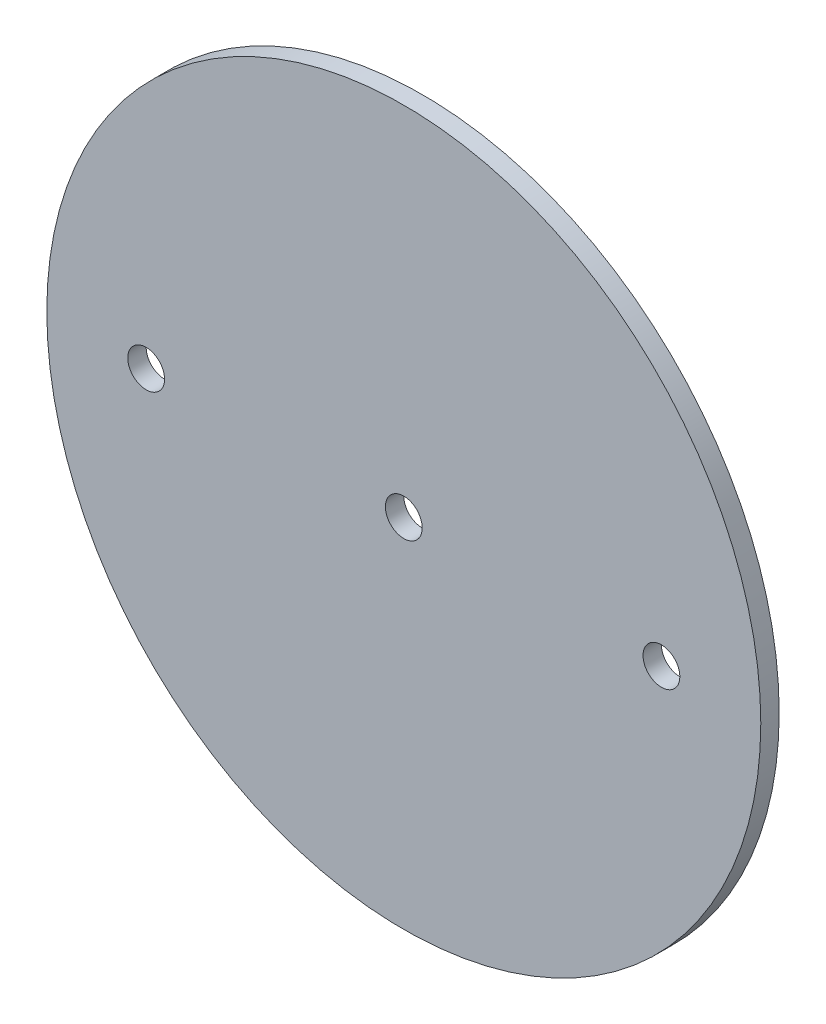
from build123d import *

# Parameters (mm, degrees)
SKETCH1_R                   = 61.595
BOSS_EXTRUDE1_DEPTH         = 1.5875
F_1_4_0_25_DIAMETER_HOLE1_D = 6.35


with BuildPart() as part:
    # Sketch1 → Boss-Extrude1 (new body, symmetric)
    with BuildSketch(Plane.XY):
        Circle(SKETCH1_R)
    extrude(amount=BOSS_EXTRUDE1_DEPTH, both=True)

    # 1/4 (0.25) Diameter Hole1 (through all)
    with Locations(Plane.XY.offset(1.5875)):
        with Locations((-44.45, 0), (0, 0), (44.45, 0)):
            Hole(F_1_4_0_25_DIAMETER_HOLE1_D / 2)


solid = part.part
